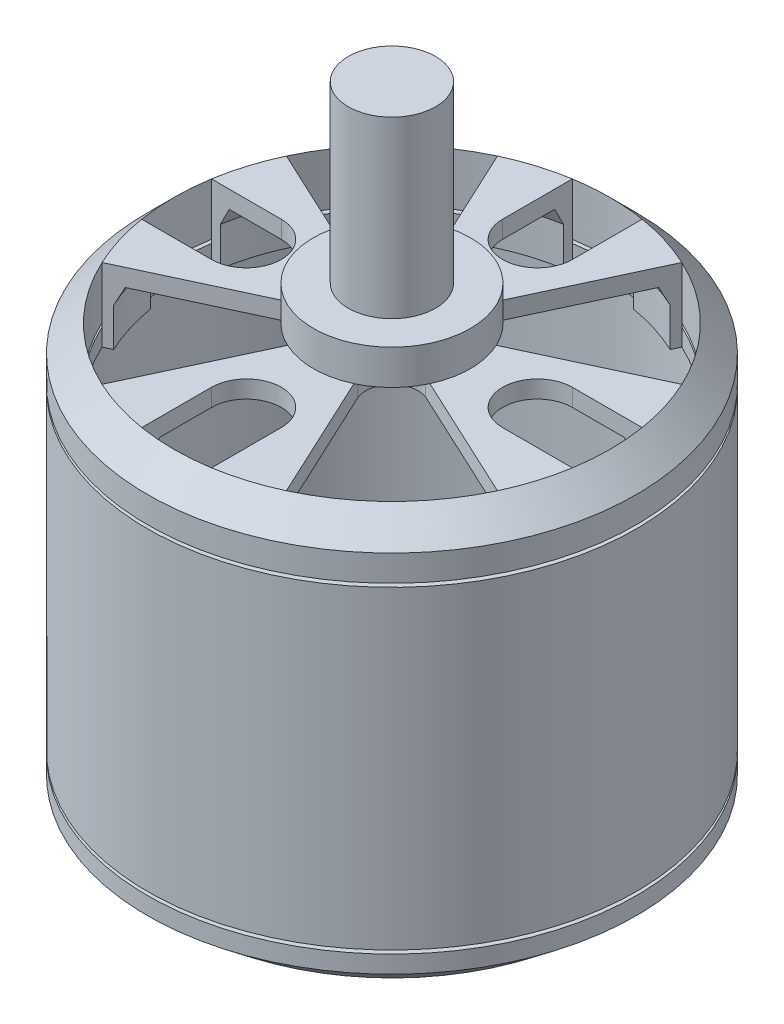
from build123d import *

# Parameters (mm, degrees)
CUT_EXTRUDE_1_DEPTH      = 10
PATTERN_CIRCULAR_1_COUNT = 4
SKETCH_3_R               = 3
SKETCH_3_R_2             = 1.5
CUT_EXTRUDE_2_DEPTH      = 5


with BuildPart() as part:
    # 草图1 → 旋转2 (revolve)
    with BuildSketch(Plane(origin=(0, 0, 0), x_dir=(0, 0, -1), z_dir=(1, 0, 0))):
        Polygon((13.999479922, 22.7), (12.5, 24.2), (4.5, 24.2), (4.5, 26.2), (2.5, 26.2), (2.5, 36.2), (0, 36.2), (0, 23.2), (11.5, 23.2), (11.999479922, 22.2), (11.999479922, 20), (12.999479922, 20), (12.999479922, 4), (4.249479922, 4), (4.249479922, 3), (0, 3), (0, 0), (0.75, 0), (0.75, 0.540825023), (1.5, 0.540825023), (1.5, 0.2), (12, 0.2), (14, 1.8), (14, 2.8), (10, 2.8), (10, 3), (13.999479922, 3), (13.999479922, 21), (12.499479922, 21), (12.499479922, 21.2), (13.999479922, 21.2), align=None)
    revolve(axis=Axis((0, 0, 0), (0, 1, 0)))

    # 草图2 → 切除-拉伸1 (cut)
    with BuildSketch(Plane(origin=(0, 24.2, 0), x_dir=(1, 0, 0), z_dir=(0, 1, 0))):
        with BuildLine():
            Line((-2, 12.338962679), (-2, 8.338962679))
            ThreePointArc((-2, 8.338962679), (0, 6.338962679), (2, 8.338962679))
            Line((2, 8.338962679), (2, 12.338962679))
            ThreePointArc((2, 12.338962679), (0, 12.5), (-2, 12.338962679))
        make_face()
        with BuildLine():
            Line((-5.282728272, 11.328847338), (-1.690473047, 3.625231148))
            ThreePointArc((-1.690473047, 3.625231148), (-2.032137638, 2.032137638), (-3.625231148, 1.690473047))
            Line((-3.625231148, 1.690473047), (-11.328847338, 5.282728272))
            ThreePointArc((-11.328847338, 5.282728272), (-8.838834765, 8.838834765), (-5.282728272, 11.328847338))
        make_face()
    cut_extrude_1 = extrude(amount=-CUT_EXTRUDE_1_DEPTH, mode=Mode.SUBTRACT)

    # 阵列(圆周)1: 切除-拉伸1 ×4 about axis
    pattern_circular_1_axis = Axis((0, -1.41, 0), (0, 1, 0))
    for i in range(1, PATTERN_CIRCULAR_1_COUNT):
        add(cut_extrude_1.rotate(pattern_circular_1_axis, i * 360 / PATTERN_CIRCULAR_1_COUNT), mode=Mode.SUBTRACT)

    # 草图3 → 切除-拉伸2 (cut)
    with BuildSketch(Plane.XZ.offset(-0.2)):
        with Locations((8, 0)):
            Circle(SKETCH_3_R)
        with Locations((0, 8)):
            Circle(SKETCH_3_R)
        with Locations((-8, 0)):
            Circle(SKETCH_3_R)
        with Locations((0, -8)):
            Circle(SKETCH_3_R)
        with Locations((6.333333333, 7.080881929)):
            Circle(SKETCH_3_R_2)
        with Locations((-6.333333333, -7.080881929)):
            Circle(SKETCH_3_R_2)
        with Locations((-5.96284794, 5.333333333)):
            Circle(SKETCH_3_R_2)
        with Locations((5.96284794, -5.333333333)):
            Circle(SKETCH_3_R_2)
    extrude(amount=-CUT_EXTRUDE_2_DEPTH, mode=Mode.SUBTRACT)


solid = part.part
